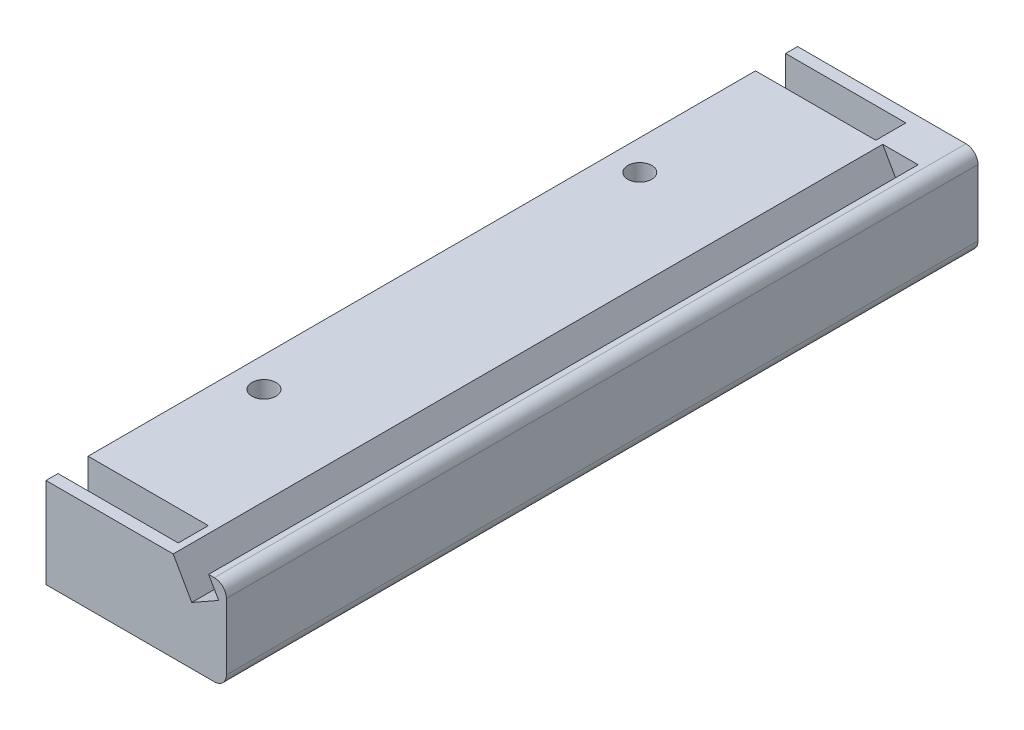
from build123d import *

# Parameters (mm, degrees)
SALIENTE_EXTRUIR1_DEPTH = 111
SALIENTE_EXTRUIR2_DEPTH = 5
CROQUIS3_W              = 20
CROQUIS3_H              = 5
SALIENTE_EXTRUIR3_DEPTH = 2
SALIENTE_EXTRUIR4_DEPTH = 5
SALIENTE_EXTRUIR5_DEPTH = 2
CROQUIS6_R              = 2
CORTAR_EXTRUIR1_DEPTH   = 41
CROQUIS7_R              = 4
CORTAR_EXTRUIR2_DEPTH   = 4
CORTAR_EXTRUIR4_DEPTH   = 118


with BuildPart() as part:
    # Croquis1 → Saliente-Extruir1 (new body)
    with BuildSketch(Plane.XY):
        with BuildLine():
            Line((0, 5), (0, 0))
            Line((0, 0), (28, 0))
            ThreePointArc((28, 0), (29.414213562, 0.585786438), (30, 2))
            Line((30, 2), (30, 13))
            ThreePointArc((30, 13), (29.414213562, 14.414213562), (28, 15))
            Line((28, 15), (0, 15))
            Line((0, 15), (0, 10))
            Line((0, 10), (20, 10))
            Line((20, 10), (20, 5))
            Line((20, 5), (0, 5))
        make_face()
    extrude(amount=SALIENTE_EXTRUIR1_DEPTH)

    # Croquis2 → Saliente-Extruir2 (add)
    with BuildSketch(Plane.XY.offset(111)):
        with BuildLine():
            Line((20, 15), (20, 10))
            Line((20, 10), (20, 5))
            Line((20, 5), (0, 5))
            Line((0, 5), (0, 0))
            Line((0, 0), (28, 0))
            ThreePointArc((28, 0), (29.414213562, 0.585786438), (30, 2))
            Line((30, 2), (30, 13))
            ThreePointArc((30, 13), (29.414213562, 14.414213562), (28, 15))
            Line((28, 15), (20, 15))
        make_face()
    extrude(amount=SALIENTE_EXTRUIR2_DEPTH)

    # Croquis3 → Saliente-Extruir3 (add)
    with BuildSketch(Plane.XY.offset(116)):
        Polygon((20, 10), (20, 15), (11, 15), (0, 15), (0, 10), align=None)
        with BuildLine():
            Line((28, 15), (20, 15))
            Line((20, 15), (20, 10))
            Line((20, 10), (20, 5))
            Line((20, 5), (0, 5))
            Line((0, 5), (0, 0))
            Line((0, 0), (28, 0))
            ThreePointArc((28, 0), (29.414213562, 0.585786438), (30, 2))
            Line((30, 2), (30, 13))
            ThreePointArc((30, 13), (29.414213562, 14.414213562), (28, 15))
        make_face()
        with Locations((10, 7.5)):
            Rectangle(CROQUIS3_W, CROQUIS3_H)
    extrude(amount=SALIENTE_EXTRUIR3_DEPTH)

    # Croquis4 → Saliente-Extruir4 (add)
    with BuildSketch(Plane(origin=(0, 0, 0), x_dir=(-1, 0, 0), z_dir=(0, 0, -1))):
        with BuildLine():
            Line((-20, 5), (-20, 10))
            Line((-20, 10), (-20, 15))
            Line((-20, 15), (-28, 15))
            ThreePointArc((-28, 15), (-29.414213562, 14.414213562), (-30, 13))
            Line((-30, 13), (-30, 2))
            ThreePointArc((-30, 2), (-29.414213562, 0.585786438), (-28, 0))
            Line((-28, 0), (0, 0))
            Line((0, 0), (0, 5))
            Line((0, 5), (-20, 5))
        make_face()
    extrude(amount=SALIENTE_EXTRUIR4_DEPTH)

    # Croquis5 → Saliente-Extruir5 (add)
    with BuildSketch(Plane(origin=(0, 0, -5), x_dir=(-1, 0, 0), z_dir=(0, 0, -1))):
        with BuildLine():
            Line((0, 15), (-28, 15))
            ThreePointArc((-28, 15), (-29.414213562, 14.414213562), (-30, 13))
            Line((-30, 13), (-30, 2))
            ThreePointArc((-30, 2), (-29.414213562, 0.585786438), (-28, 0))
            Line((-28, 0), (0, 0))
            Line((0, 0), (0, 15))
        make_face()
    extrude(amount=SALIENTE_EXTRUIR5_DEPTH)

    # Croquis6 → Cortar-Extruir1 (cut)
    with BuildSketch(Plane.XZ):
        with Locations((5, 24.25)):
            Circle(CROQUIS6_R)
        with Locations((5, 86.75)):
            Circle(CROQUIS6_R)
    extrude(amount=-CORTAR_EXTRUIR1_DEPTH, mode=Mode.SUBTRACT)

    # Croquis7 → Cortar-Extruir2 (cut)
    with BuildSketch(Plane(origin=(0, 0, 0), x_dir=(-1, 0, 0), z_dir=(0, -1, 0))):
        with Locations((-5, -24.25)):
            Circle(CROQUIS7_R)
        with Locations((-5, -86.75)):
            Circle(CROQUIS7_R)
    extrude(amount=-CORTAR_EXTRUIR2_DEPTH, mode=Mode.SUBTRACT)

    # Croquis9 → Cortar-Extruir4 (cut)
    with BuildSketch(Plane.XY.offset(118)):
        Polygon((27.046454018, 15), (28.719274454, 12.085683765), (24.239354869, 9.549004814), (21.152820727, 15), align=None)
    extrude(amount=-CORTAR_EXTRUIR4_DEPTH, mode=Mode.SUBTRACT)


solid = part.part
